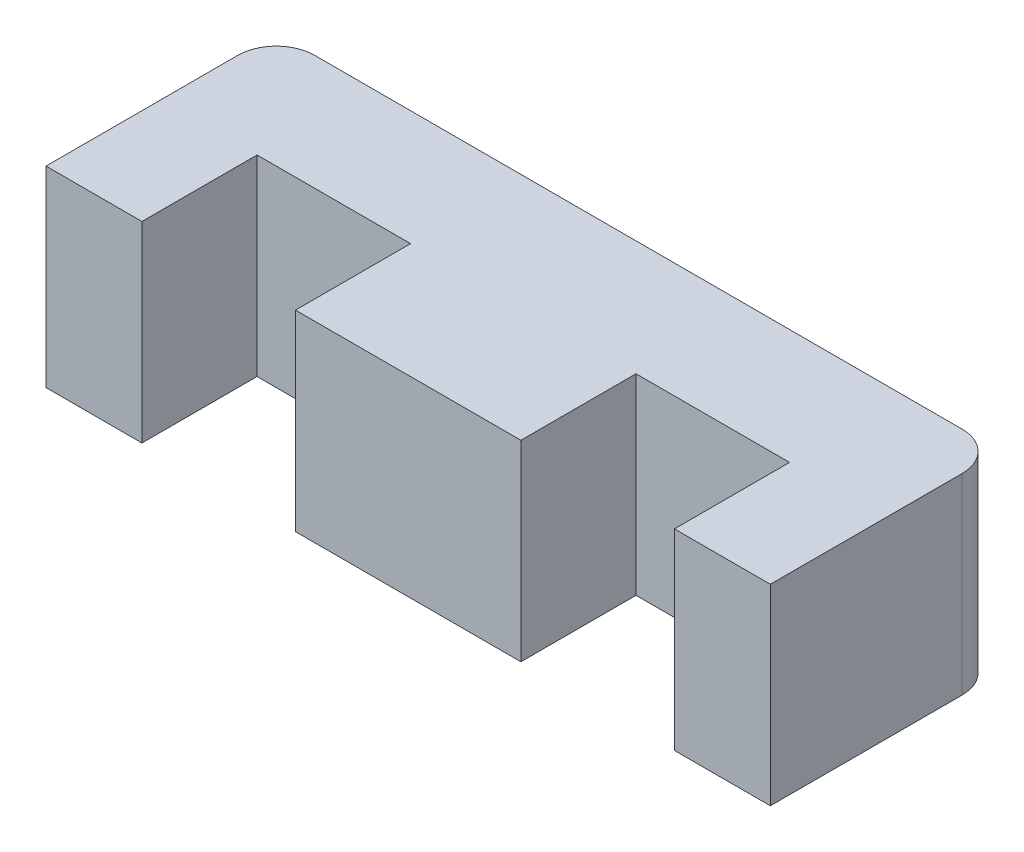
from build123d import *

# Parameters (mm, degrees)
BOSS_EXTRUDE1_DEPTH = 10
FILLET1_R           = 2


with BuildPart() as part:
    # Sketch1 → Boss-Extrude1 (new body)
    with BuildSketch(Plane(origin=(0, 0, 0), x_dir=(1, 0, 0), z_dir=(0, 1, 0))):
        Polygon((0, 0), (8, 0), (8, -6), (19.75, -6), (19.75, 0), (27.75, 0), (27.75, -6), (32.75, -6), (32.75, 6), (-5, 6), (-5, -6), (0, -6), align=None)
    extrude(amount=BOSS_EXTRUDE1_DEPTH)

    # Fillet1
    fillet1_edges = [part.edges().sort_by_distance(p)[0] for p in [
        (-5, 5, -6),
        (32.75, 5, -6),
    ]]
    fillet(fillet1_edges, radius=FILLET1_R)


solid = part.part
